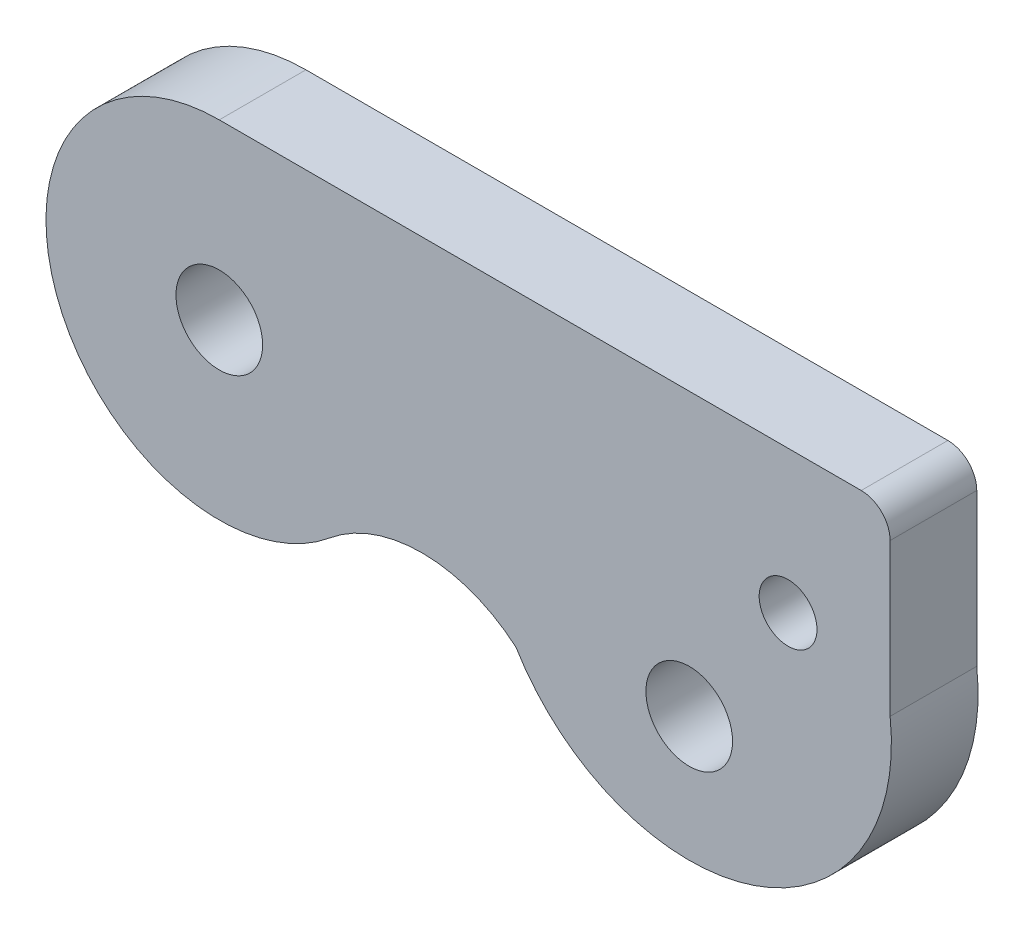
from build123d import *

# Parameters (mm, degrees)
SKETCH1_R           = 1.5
SKETCH1_R_2         = 1
BOSS_EXTRUDE1_DEPTH = 3


with BuildPart() as part:
    # Sketch1 → Boss-Extrude1 (new body)
    with BuildSketch(Plane.XY):
        with BuildLine():
            Line((0, 0), (22, 0))
            Line((22, 0), (22.223388106, 0))
            ThreePointArc((22.223388106, 0), (22.930494887, -0.292893219), (23.223388106, -1))
            Line((23.223388106, -1), (23.223388106, -6.271970615))
            ThreePointArc((23.223388106, -6.271970615), (18.521001308, -13.695477275), (10.2692294, -10.674028436))
            ThreePointArc((10.2692294, -10.674028436), (7.057961936, -9.471675777), (3.827272257, -10.620821039))
            ThreePointArc((3.827272257, -10.620821039), (-5.644684501, -8.034093627), (0, 0))
        make_face()
        with Locations((0, -6)):
            Circle(SKETCH1_R, mode=Mode.SUBTRACT)
        with Locations((19.690645816, -4.936162338)):
            Circle(SKETCH1_R_2, mode=Mode.SUBTRACT)
        with Locations((16.268762771, -9.747966239)):
            Circle(SKETCH1_R, mode=Mode.SUBTRACT)
    extrude(amount=BOSS_EXTRUDE1_DEPTH)


solid = part.part
